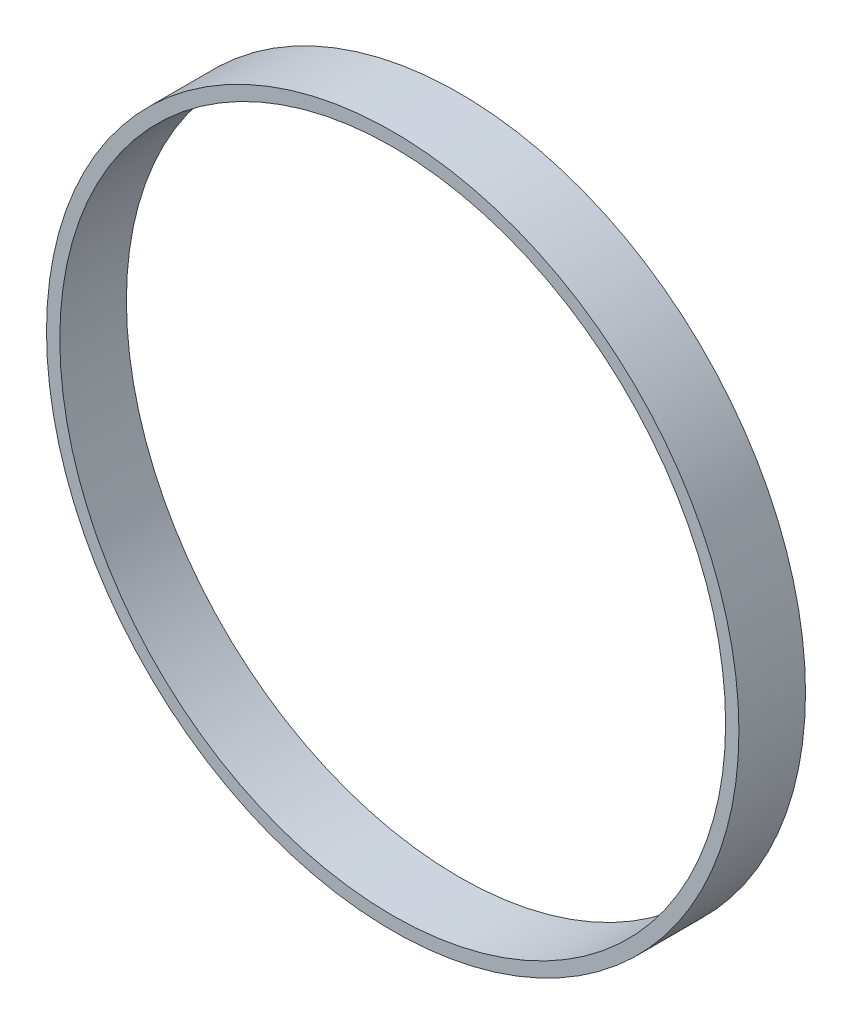
from build123d import *

# Parameters (mm, degrees)
SKETCH1_R           = 104
SKETCH1_R_2         = 100
BOSS_EXTRUDE1_DEPTH = 20


with BuildPart() as part:
    # Sketch1 → Boss-Extrude1 (new body)
    with BuildSketch(Plane.XY):
        Circle(SKETCH1_R)
        Circle(SKETCH1_R_2, mode=Mode.SUBTRACT)
    extrude(amount=BOSS_EXTRUDE1_DEPTH)


solid = part.part
